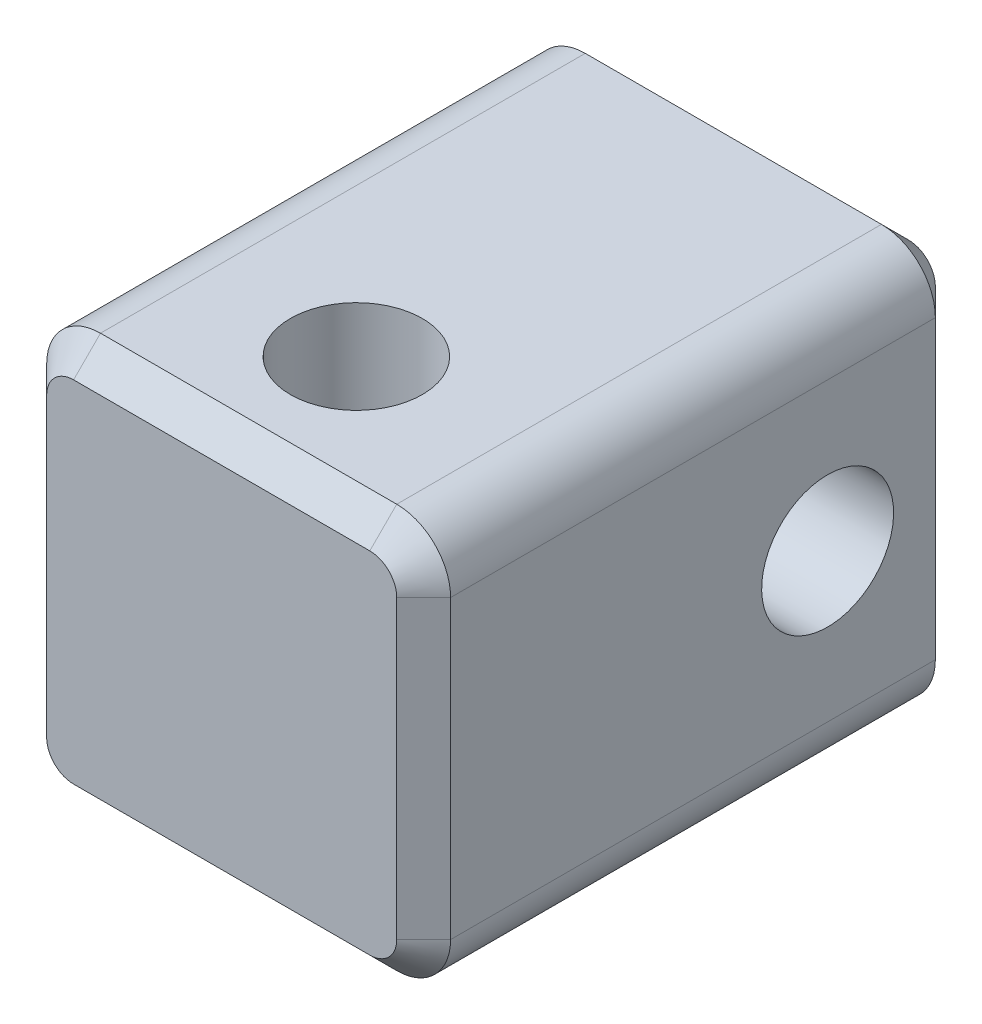
from build123d import *

# Parameters (mm, degrees)
SKETCH_1_W          = 15
SKETCH_1_H          = 15
EXTRUDE_1_DEPTH     = 20
SKETCH_2_R          = 2.45
CUT_EXTRUDE_1_DEPTH = 27.100766272
SKETCH_3_R          = 2.45
CUT_EXTRUDE_2_DEPTH = 27.100766272
FILLET_1_R          = 2
CHAMFER_1_SIZE      = 1


with BuildPart() as part:
    # ｽｹｯﾁ1 → ﾎﾞｽ - 押し出し1 (new body)
    with BuildSketch(Plane.XY):
        Rectangle(SKETCH_1_W, SKETCH_1_H)
    extrude(amount=EXTRUDE_1_DEPTH)

    # ｽｹｯﾁ2 → ｶｯﾄ - 押し出し1 (cut, through all)
    with BuildSketch(Plane(origin=(7.5, 0, 0), x_dir=(0, 0, -1), z_dir=(1, 0, 0))):
        with Locations((-5, 0)):
            Circle(SKETCH_2_R)
    extrude(amount=-CUT_EXTRUDE_1_DEPTH, mode=Mode.SUBTRACT)

    # ｽｹｯﾁ3 → ｶｯﾄ - 押し出し2 (cut, through all)
    with BuildSketch(Plane(origin=(0, 7.5, 0), x_dir=(1, 0, 0), z_dir=(0, 1, 0))):
        with Locations((0, -15)):
            Circle(SKETCH_3_R)
    extrude(amount=-CUT_EXTRUDE_2_DEPTH, mode=Mode.SUBTRACT)

    # ﾌｨﾚｯﾄ1
    fillet_1_edges = [part.edges().sort_by_distance(p)[0] for p in [
        (7.5, -7.5, 10),
        (-7.5, -7.5, 10),
        (-7.5, 7.5, 10),
        (7.5, 7.5, 10),
    ]]
    fillet(fillet_1_edges, radius=FILLET_1_R)

    # 面取り1
    chamfer_1_edges = [part.edges().sort_by_distance(p)[0] for p in [
        (-6.914213562, -6.914213562, 20),
        (-7.5, 0, 20),
        (-6.914213562, 6.914213562, 20),
        (0, 7.5, 20),
        (6.914213562, 6.914213562, 20),
        (7.5, 0, 20),
        (6.914213562, -6.914213562, 20),
        (0, -7.5, 20),
        (6.914213562, 6.914213562, 0),
        (0, 7.5, 0),
        (-6.914213562, 6.914213562, 0),
        (-7.5, 0, 0),
        (-6.914213562, -6.914213562, 0),
        (0, -7.5, 0),
        (6.914213562, -6.914213562, 0),
        (7.5, 0, 0),
    ]]
    chamfer(chamfer_1_edges, length=CHAMFER_1_SIZE)


solid = part.part
